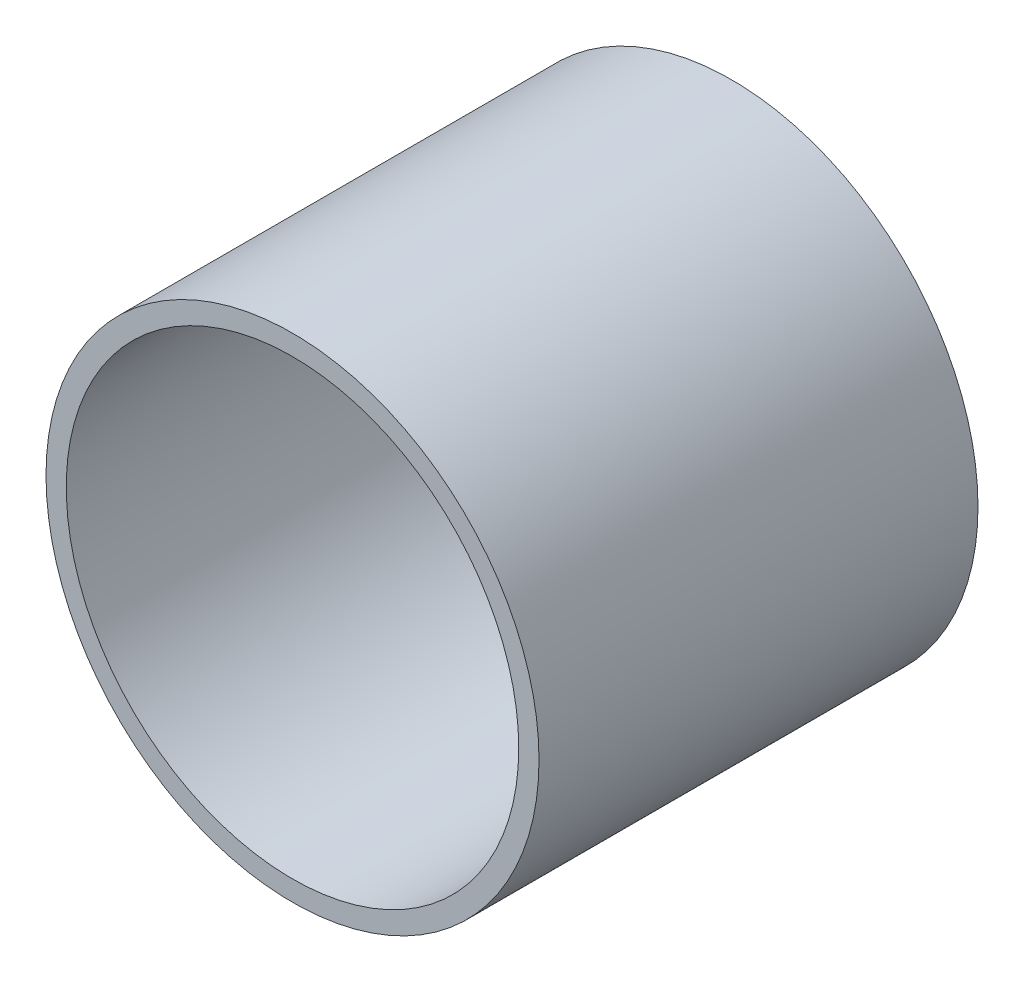
from build123d import *

# Parameters (mm, degrees)
ESBO_O1_R                = 36.5
ESBO_O1_R_2              = 33.5
RESSALTO_EXTRUS_O1_DEPTH = 65
ESBO_O1_3_R              = 33.5
RESSALTO_EXTRUS_O2_DEPTH = 3


with BuildPart() as part:
    # Esboço1 → Ressalto-extrusão1 (new body)
    with BuildSketch(Plane.XY):
        Circle(ESBO_O1_R)
        Circle(ESBO_O1_R_2, mode=Mode.SUBTRACT)
    extrude(amount=RESSALTO_EXTRUS_O1_DEPTH)

    # Esboço1<3> → Ressalto-extrusão2 (add)
    with BuildSketch(Plane.XY):
        Circle(ESBO_O1_3_R)
    extrude(amount=RESSALTO_EXTRUS_O2_DEPTH)


solid = part.part
